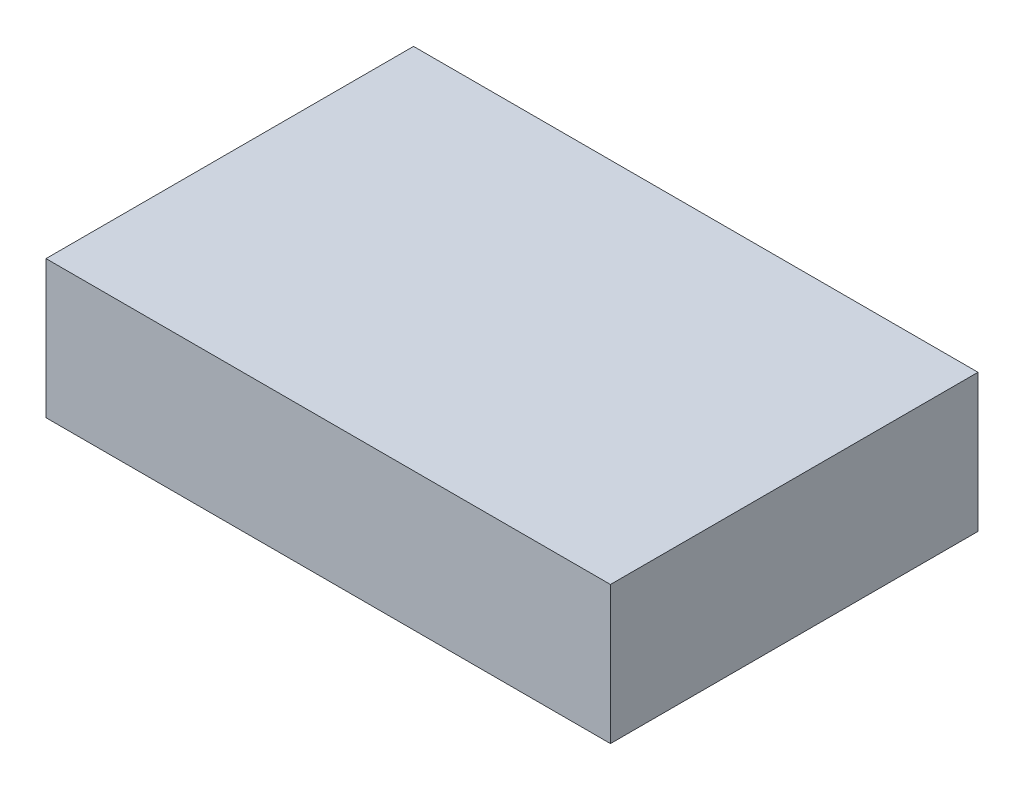
from build123d import *

# Parameters (mm, degrees)
SKETCH1_W           = 86
SKETCH1_H           = 56
BOSS_EXTRUDE1_DEPTH = 21


with BuildPart() as part:
    # Sketch1 → Boss-Extrude1 (new body)
    with BuildSketch(Plane(origin=(0, 0, 0), x_dir=(1, 0, 0), z_dir=(0, 1, 0))):
        Rectangle(SKETCH1_W, SKETCH1_H)
    extrude(amount=BOSS_EXTRUDE1_DEPTH)


solid = part.part
